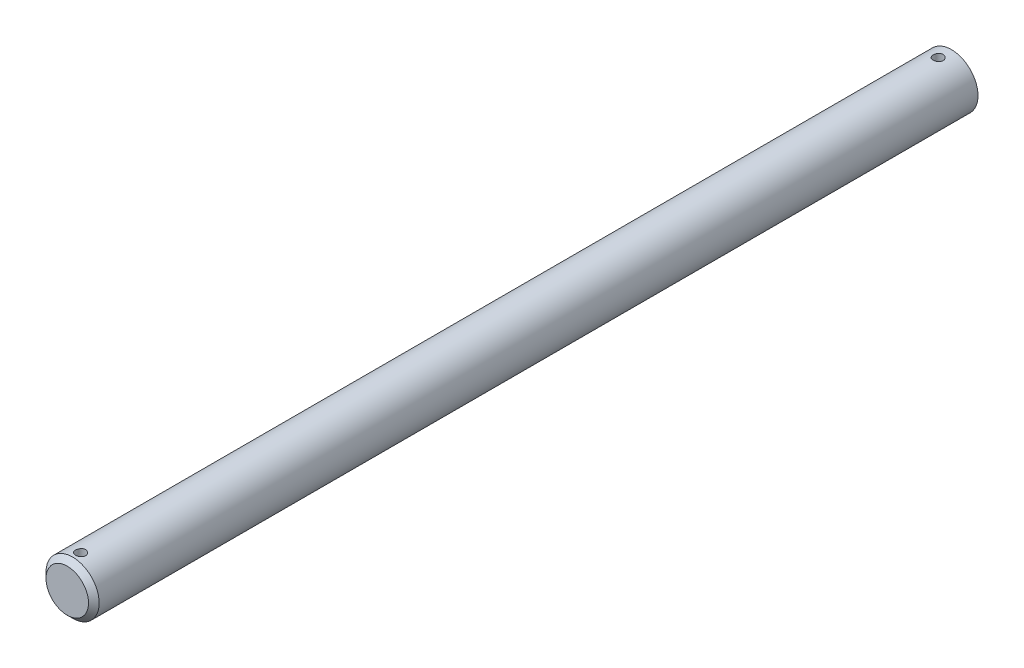
from build123d import *

# Parameters (mm, degrees)
SKETCH3_R               = 3.175
BOSS_EXTRUDE1_DEPTH     = 304.8
CHAMFER1_SIZE           = 0.635
CUT_EXTRUDE1_START      = -105.627050112
SKETCH4_R               = 3.175
CUT_EXTRUDE1_DEPTH      = 504.972949888
SKETCH5_R               = 0.5953125
CUT_EXTRUDE2_DEPTH      = 4.175
CUT_EXTRUDE2_DEPTH_BACK = 4.175


with BuildPart() as part:
    # Sketch3 → Boss-Extrude1 (new body, symmetric)
    with BuildSketch(Plane.XY):
        Circle(SKETCH3_R)
    extrude(amount=BOSS_EXTRUDE1_DEPTH, both=True)

    # Chamfer1
    chamfer1_edges = [part.edges().sort_by_distance(p)[0] for p in [
        (-3.175, 0, -304.8),
        (-3.175, 0, 304.8),
    ]]
    chamfer(chamfer1_edges, length=CHAMFER1_SIZE)

    # Sketch4 → Cut-Extrude1 (cut, through all)
    with BuildSketch(Plane.XY.offset(304.8).offset(CUT_EXTRUDE1_START)):
        Circle(SKETCH4_R)
    extrude(amount=-CUT_EXTRUDE1_DEPTH, mode=Mode.SUBTRACT)

    # Sketch5 → Cut-Extrude2 (cut, two sides)
    with BuildSketch(Plane(origin=(0, 0, 0), x_dir=(1, 0, 0), z_dir=(0, 1, 0))) as cut_extrude2_sk:
        with Locations((0, -200.760449888)):
            Circle(SKETCH5_R)
        with Locations((0, -303.2125)):
            Circle(SKETCH5_R)
    extrude(amount=CUT_EXTRUDE2_DEPTH, mode=Mode.SUBTRACT)
    extrude(cut_extrude2_sk.sketch, amount=-CUT_EXTRUDE2_DEPTH_BACK, mode=Mode.SUBTRACT)


solid = part.part
